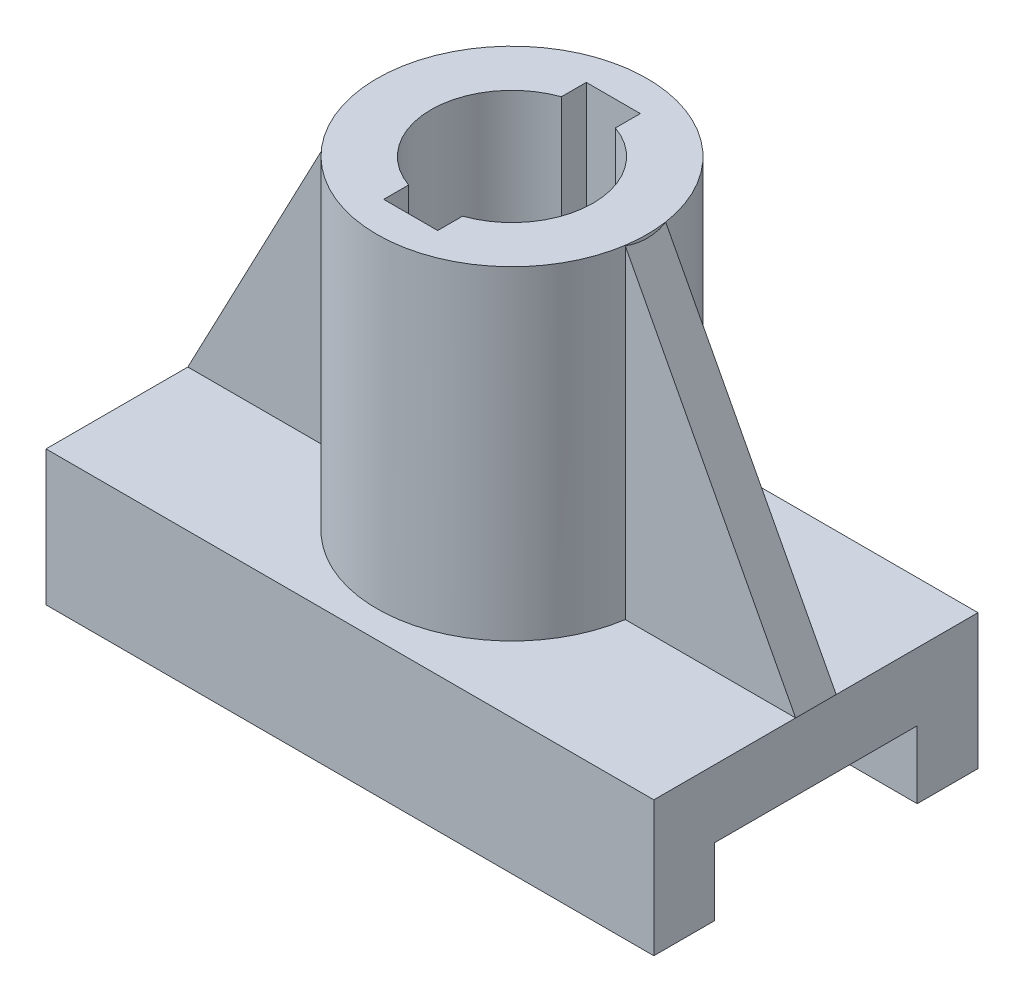
from build123d import *

# Parameters (mm, degrees)
SKETCH1_W               = 90
SKETCH1_H               = 48
BOSS_EXTRUDE1_DEPTH     = 20
SKETCH2_R               = 20
BOSS_EXTRUDE2_DEPTH     = 48
SKETCH3_R               = 12
CUT_EXTRUDE1_DEPTH      = 48
SKETCH4_W               = 8
SKETCH4_H               = 30
CUT_EXTRUDE2_DEPTH      = 48
SKETCH5_W               = 30
SKETCH5_H               = 10
CUT_EXTRUDE4_DEPTH      = 116.325625947
CUT_EXTRUDE4_DEPTH_BACK = 116.325625947
RIB5_REACH              = 87
SKETCH7_WALL_W          = 225.677276384
SKETCH7_WALL_H          = 6


with BuildPart() as part:
    # Sketch1 → Boss-Extrude1 (new body)
    with BuildSketch(Plane(origin=(0, 0, 0), x_dir=(1, 0, 0), z_dir=(0, 1, 0))):
        Rectangle(SKETCH1_W, SKETCH1_H)
    extrude(amount=BOSS_EXTRUDE1_DEPTH)

    # Sketch2 → Boss-Extrude2 (add)
    with BuildSketch(Plane(origin=(0, 20, 0), x_dir=(1, 0, 0), z_dir=(0, 1, 0))):
        with Locations(Location((0, 0, 0), (0, 0, 270))):
            Circle(SKETCH2_R)
    extrude(amount=BOSS_EXTRUDE2_DEPTH)

    # Sketch3 → Cut-Extrude1 (cut)
    with BuildSketch(Plane(origin=(0, 68, 0), x_dir=(1, 0, 0), z_dir=(0, 1, 0))):
        with Locations(Location((0, 0, 0), (0, 0, 270))):
            Circle(SKETCH3_R)
    extrude(amount=-CUT_EXTRUDE1_DEPTH, mode=Mode.SUBTRACT)

    # Sketch4 → Cut-Extrude2 (cut)
    with BuildSketch(Plane(origin=(0, 68, 0), x_dir=(1, 0, 0), z_dir=(0, 1, 0))):
        Rectangle(SKETCH4_W, SKETCH4_H)
    extrude(amount=-CUT_EXTRUDE2_DEPTH, mode=Mode.SUBTRACT)

    # Sketch5 → Cut-Extrude4 (cut, two sides)
    with BuildSketch(Plane.ZY.offset(45)) as cut_extrude4_sk:
        with Locations((0, 5)):
            Rectangle(SKETCH5_W, SKETCH5_H)
    extrude(amount=CUT_EXTRUDE4_DEPTH, mode=Mode.SUBTRACT)
    extrude(cut_extrude4_sk.sketch, amount=-CUT_EXTRUDE4_DEPTH_BACK, mode=Mode.SUBTRACT)

    # Sketch7 wall → Rib5 (add, up to next)
    with BuildSketch(Plane(origin=(32.5, 43.75, 0), x_dir=(0.465746432833, -0.884918222382, 0), z_dir=(0.884918222382, 0.465746432833, 0)), mode=Mode.PRIVATE) as rib5_sk1:
        Rectangle(SKETCH7_WALL_W, SKETCH7_WALL_H)
    rib5_tool1 = extrude(rib5_sk1.sketch, amount=-RIB5_REACH, mode=Mode.PRIVATE) - part.part
    add(rib5_tool1.solids().sort_by_distance((32.5, 43.75, 0))[0])

    # Mirror1: part across plane


with BuildPart() as part_1:
    add(part.part)
    add(part.part.mirror(Plane(origin=(0, 0, 0), x_dir=(0, 0, 1), z_dir=(1, 0, 0))))


solid = part_1.part
